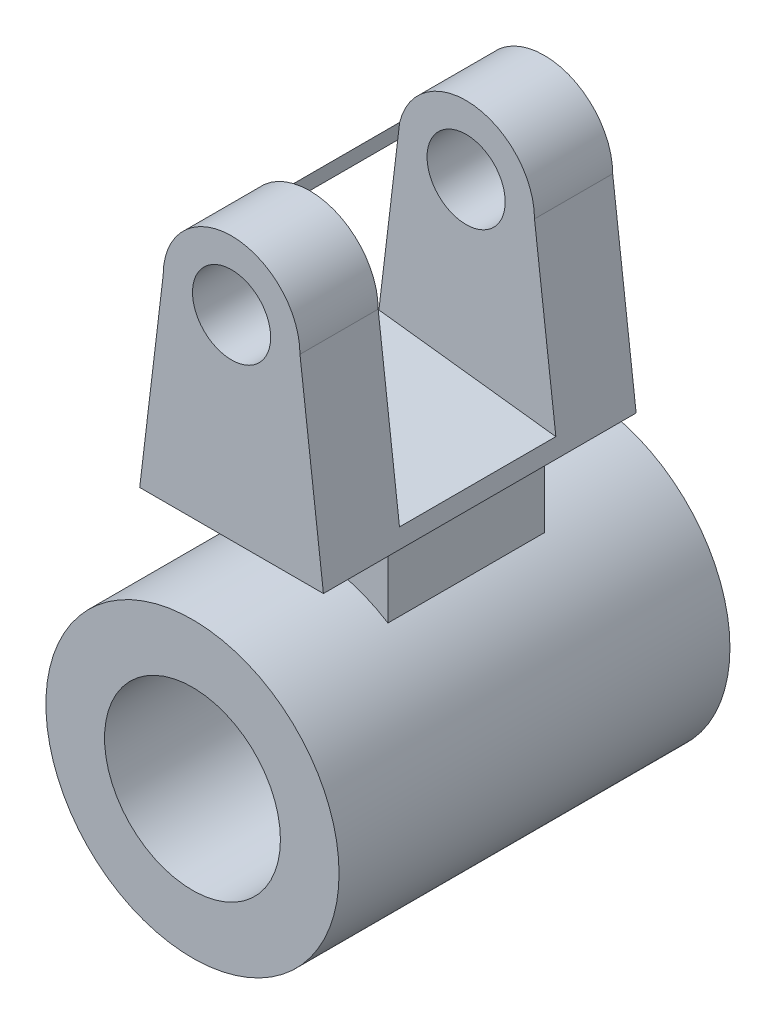
from build123d import *

# Parameters (mm, degrees)
SKETCH1_R           = 37.5
SKETCH1_R_2         = 22.5
BOSS_EXTRUDE1_DEPTH = 50
BOSS_EXTRUDE3_DEPTH = 40
SKETCH10_R          = 10
CUT_EXTRUDE5_DEPTH  = 91
SKETCH11_W          = 40
SKETCH11_H          = 59.943754609
CUT_EXTRUDE6_DEPTH  = 71.990693952
SKETCH12_W          = 40
SKETCH12_H          = 20
BOSS_EXTRUDE8_DEPTH = 20


with BuildPart() as part:
    # Sketch1 → Boss-Extrude1 (new body, symmetric)
    with BuildSketch(Plane.XY):
        Circle(SKETCH1_R)
        Circle(SKETCH1_R_2, mode=Mode.SUBTRACT)
    extrude(amount=BOSS_EXTRUDE1_DEPTH, both=True)



with BuildPart() as body_2:
    # Sketch3 → Boss-Extrude3 (new body, symmetric)
    with BuildSketch(Plane.XY):
        with BuildLine():
            Line((-23.5, 50), (23.5, 50))
            Line((23.5, 50), (17.5, 100))
            ThreePointArc((17.5, 100), (0, 117.5), (-17.5, 100))
            Line((-17.5, 100), (-23.5, 50))
        make_face()
    extrude(amount=BOSS_EXTRUDE3_DEPTH, both=True)

    # Sketch10 → Cut-Extrude5 (cut, through all)
    with BuildSketch(Plane.XY.offset(40)):
        with Locations((0, 100)):
            Circle(SKETCH10_R)
    extrude(amount=-CUT_EXTRUDE5_DEPTH, mode=Mode.SUBTRACT)

    # Sketch11 → Cut-Extrude6 (cut, through all)
    with BuildSketch(Plane(origin=(-29.081230284, 3.489747634, 0), x_dir=(0, 0, 1), z_dir=(-0.992876838, 0.119145221, 0))):
        with Locations((0, 86.815806545)):
            Rectangle(SKETCH11_W, SKETCH11_H)
    extrude(amount=-CUT_EXTRUDE6_DEPTH, mode=Mode.SUBTRACT)


with BuildPart() as part_1:
    add(part.part)

    add(body_2.part)  # Boss-Extrude8 merges body 2
    # Sketch12 → Boss-Extrude8 (add, symmetric)
    with BuildSketch(Plane.XY):
        with Locations((0, 40)):
            Rectangle(SKETCH12_W, SKETCH12_H)
    extrude(amount=BOSS_EXTRUDE8_DEPTH, both=True)


solid = part_1.part
